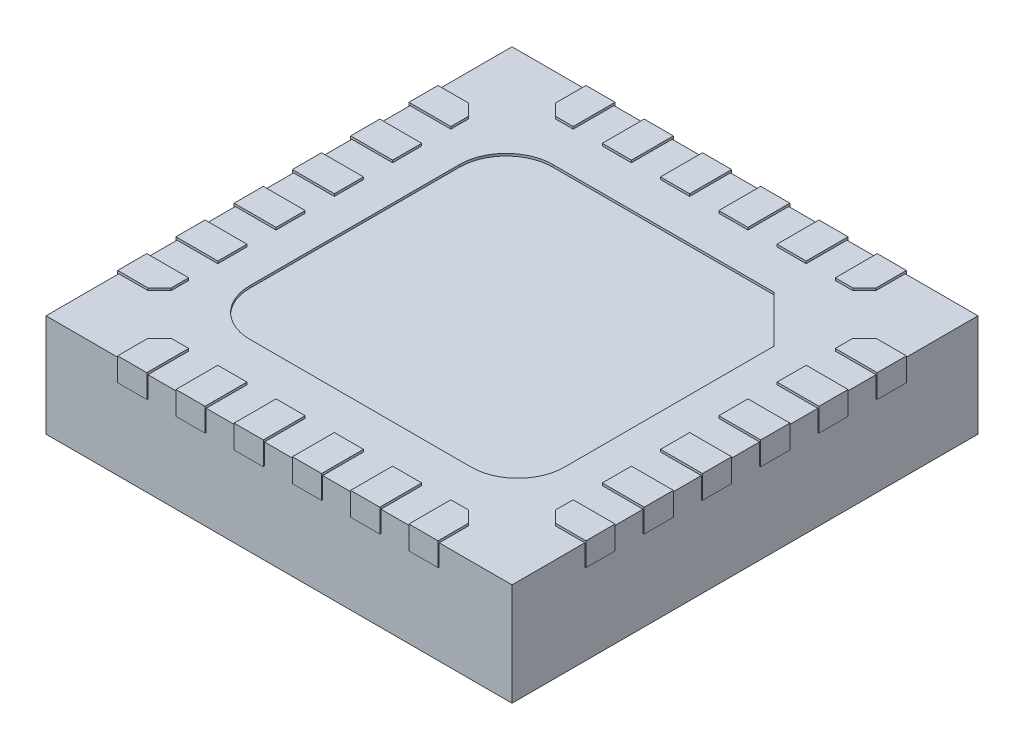
from build123d import *

# Parameters (mm, degrees)
SKETCH1_W                = 4
SKETCH1_H                = 4
BOSS_EXTRUDE1_DEPTH      = 0.88
BOSS_EXTRUDE3_DEPTH      = 0.02
BOSS_EXTRUDE3_DEPTH_BACK = 0.18
CUT_EXTRUDE1_DEPTH       = 0.02
SKETCH4_R                = 0.1
CUT_EXTRUDE2_DEPTH       = 0.02


with BuildPart() as part:
    # Sketch1 → Boss-Extrude1 (new body)
    with BuildSketch(Plane(origin=(0, 0, 0), x_dir=(1, 0, 0), z_dir=(0, 1, 0))):
        Rectangle(SKETCH1_W, SKETCH1_H)
    extrude(amount=BOSS_EXTRUDE1_DEPTH)

    # Sketch2 → Boss-Extrude3 (add, two sides)
    with BuildSketch(Plane(origin=(0, 0.88, 0), x_dir=(1, 0, 0), z_dir=(0, 1, 0))) as boss_extrude3_sk:
        Polygon((2, 1.375012124), (1.750012124, 1.375012124), (1.65, 1.275), (1.65, 1.124992652), (2, 1.124992652), (2.01, 1.124992652), (2.01, 1.375012124), align=None)
        Polygon((2, 0.624996326), (1.65, 0.624996326), (1.65, 0.875015798), (2, 0.875015798), (2.01, 0.875015798), (2.01, 0.624996326), align=None)
        Polygon((2, 0.125), (1.65, 0.125), (1.65, 0.375019472), (2, 0.375019472), (2.01, 0.374998163), (2.01, 0.125), align=None)
        Polygon((2, -0.374996326), (1.65, -0.374996326), (1.65, -0.124976854), (2, -0.124976854), (2.01, -0.124976854), (2.01, -0.374996326), align=None)
        Polygon((2, -0.874992652), (1.65, -0.874992652), (1.65, -0.62497318), (2, -0.62497318), (2.01, -0.62497318), (2.01, -0.874992652), align=None)
        Polygon((2, -1.374988978), (1.75, -1.374988978), (1.65, -1.274988978), (1.65, -1.124969506), (2, -1.124969506), (2.01, -1.124969506), (2.01, -1.374988978), align=None)
        Polygon((-1.375, -2), (-1.375, -2.01), (-1.125, -2.01), (-1.125, -2), (-1.125, -1.65), (-1.275, -1.65), (-1.375, -1.75), align=None)
        Polygon((-2, -1.124969506), (-1.65, -1.124969506), (-1.65, -1.275), (-1.75, -1.375), (-2, -1.374988978), (-2.01, -1.374988978), (-2.01, -1.124969506), align=None)
        Polygon((-2, -0.62497318), (-1.65, -0.62497318), (-1.65, -0.874992652), (-2, -0.874992652), (-2.01, -0.874992652), (-2.01, -0.62497318), align=None)
        Polygon((1.375, -2.01), (1.375, -2), (1.375, -1.75), (1.275, -1.65), (1.125, -1.65), (1.125, -2), (1.125, -2.01), align=None)
        Polygon((-2, -0.124976854), (-1.65, -0.124976854), (-1.65, -0.374996326), (-2, -0.374996326), (-2.01, -0.374996326), (-2.01, -0.124976854), align=None)
        Polygon((-2, 0.375019472), (-1.65, 0.375019472), (-1.65, 0.125), (-2, 0.125), (-2.01, 0.125), (-2.01, 0.374998163), align=None)
        Polygon((-2, 0.875015798), (-1.65, 0.875015798), (-1.65, 0.624996326), (-2, 0.624996326), (-2.01, 0.624996326), (-2.01, 0.875015798), align=None)
        Polygon((-1.65, 1.275), (-1.65, 1.124992652), (-2, 1.124992652), (-2.01, 1.124992652), (-2.01, 1.375012124), (-2, 1.375012124), (-1.75, 1.375), align=None)
        Polygon((1.125, 2.01), (1.125, 2), (1.125, 1.65), (1.275, 1.65), (1.375, 1.75), (1.375, 2), (1.375, 2.01), align=None)
        Polygon((-0.875, -1.65), (-0.875, -2), (-0.875, -2.01), (-0.625, -2.01), (-0.625, -2), (-0.625, -1.65), align=None)
        Polygon((-0.375, -1.65), (-0.375, -2), (-0.375, -2.01), (-0.125, -2.01), (-0.125, -2), (-0.125, -1.65), align=None)
        Polygon((0.125, -1.65), (0.125, -2), (0.125, -2.01), (0.375, -2.01), (0.375, -2), (0.375, -1.65), align=None)
        Polygon((0.625, -1.65), (0.625, -2), (0.625, -2.01), (0.875, -2.01), (0.875, -2), (0.875, -1.65), align=None)
        Polygon((0.875, 1.65), (0.875, 2), (0.875, 2.01), (0.625, 2.01), (0.625, 2), (0.625, 1.65), align=None)
        Polygon((0.375, 1.65), (0.375, 2), (0.375, 2.01), (0.125, 2.01), (0.125, 2), (0.125, 1.65), align=None)
        Polygon((-0.125, 1.65), (-0.125, 2), (-0.125, 2.01), (-0.375, 2.01), (-0.375, 2), (-0.375, 1.65), align=None)
        Polygon((-0.625, 1.65), (-0.625, 2), (-0.625, 2.01), (-0.875, 2.01), (-0.875, 2), (-0.875, 1.65), align=None)
        Polygon((-1.125, 1.65), (-1.125, 2), (-1.125, 2.01), (-1.375, 2.01), (-1.375, 2), (-1.375, 1.75), (-1.275, 1.65), align=None)
    extrude(amount=BOSS_EXTRUDE3_DEPTH)
    extrude(boss_extrude3_sk.sketch, amount=-BOSS_EXTRUDE3_DEPTH_BACK)

    # Sketch3 → Cut-Extrude1 (cut)
    with BuildSketch(Plane(origin=(0, 0.88, 0), x_dir=(1, 0, 0), z_dir=(0, 1, 0))):
        with BuildLine():
            Line((0.95, 1.3), (1.35, 0.9))
            Line((1.35, 0.9), (1.35, -0.9))
            ThreePointArc((1.35, -0.9), (1.232842712, -1.182842712), (0.95, -1.3))
            Line((0.95, -1.3), (-0.95, -1.3))
            ThreePointArc((-0.95, -1.3), (-1.232842712, -1.182842712), (-1.35, -0.9))
            Line((-1.35, -0.9), (-1.35, 0.9))
            ThreePointArc((-1.35, 0.9), (-1.232842712, 1.182842712), (-0.95, 1.3))
            Line((-0.95, 1.3), (0.95, 1.3))
        make_face()
    extrude(amount=-CUT_EXTRUDE1_DEPTH, mode=Mode.SUBTRACT)

    # Sketch4 → Cut-Extrude2 (cut)
    with BuildSketch(Plane.XZ):
        with Locations((1.5, -1.5)):
            Circle(SKETCH4_R)
    extrude(amount=-CUT_EXTRUDE2_DEPTH, mode=Mode.SUBTRACT)


solid = part.part
